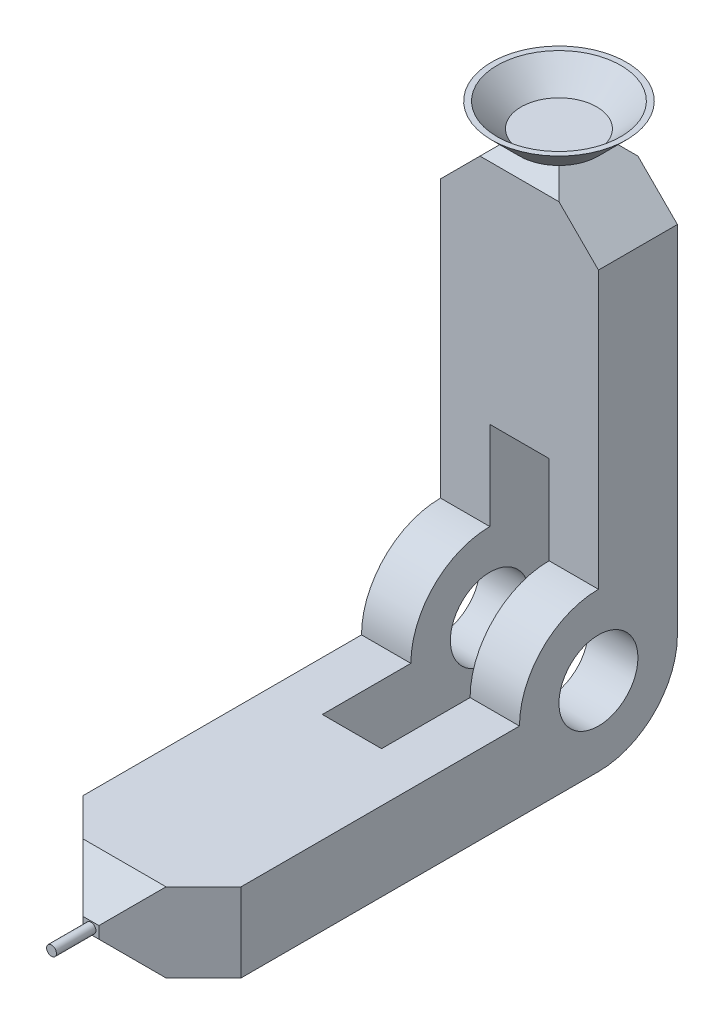
from build123d import *

# Parameters (mm, degrees)
SKETCH1_TOOL_TIP_R  = 10
BOSS_EXTRUDE1_DEPTH = 20
CHAMFER1_SIZE       = 18
CUT_EXTRUDE1_DEPTH  = 7.5
SKETCH3_TOOL_TIP_R  = 1.25
BOSS_EXTRUDE2_DEPTH = 10
CHAMFER2_SIZE       = 15


with BuildPart() as part:
    # sketch1_tool_tip → Boss-Extrude1 (new body, symmetric)
    with BuildSketch(Plane(origin=(0, 0, 0), x_dir=(0, 0, -1), z_dir=(1, 0, 0))):
        with BuildLine():
            Line((-100, 0), (-108.5, -8.5))
            Line((-108.5, -8.5), (-108.5, -11.5))
            Line((-108.5, -11.5), (-100, -20))
            Line((-100, -20), (0, -20))
            ThreePointArc((0, -20), (14.142135624, -14.142135624), (20, 0))
            Line((20, 0), (20, 100))
            Line((20, 100), (15, 105))
            Line((15, 105), (5, 105))
            Line((5, 105), (0, 100))
            Line((0, 100), (0, 20))
            ThreePointArc((0, 20), (-14.142135624, 14.142135624), (-20, 0))
            Line((-20, 0), (-100, 0))
        make_face()
        Circle(SKETCH1_TOOL_TIP_R, mode=Mode.SUBTRACT)
    extrude(amount=BOSS_EXTRUDE1_DEPTH, both=True)

    # Chamfer1
    chamfer1_edges = [part.edges().sort_by_distance(p)[0] for p in [
        (-20, -10, 108.5),
        (20, -10, 108.5),
    ]]
    chamfer(chamfer1_edges, length=CHAMFER1_SIZE)

    # sketch2_tool_tip → Cut-Extrude1 (cut, symmetric)
    with BuildSketch(Plane(origin=(0, 0, 0), x_dir=(0, 0, -1), z_dir=(1, 0, 0))):
        with BuildLine():
            Line((-42.42, -20), (0, -20))
            ThreePointArc((0, -20), (14.142135624, -14.142135624), (20, 0))
            Line((20, 0), (20, 42.42))
            Line((20, 42.42), (0, 42.42))
            Line((0, 42.42), (0, 20))
            ThreePointArc((0, 20), (-14.142135624, 14.142135624), (-20, 0))
            Line((-20, 0), (-42.42, 0))
            Line((-42.42, 0), (-42.42, -20))
        make_face()
    extrude(amount=CUT_EXTRUDE1_DEPTH, both=True, mode=Mode.SUBTRACT)

    # sketch3_tool_tip → Boss-Extrude2 (add)
    with BuildSketch(Plane.XY.offset(108.5)):
        with Locations((0, -10)):
            Circle(SKETCH3_TOOL_TIP_R)
    extrude(amount=BOSS_EXTRUDE2_DEPTH)

    # Chamfer2
    chamfer2_edges = [part.edges().sort_by_distance(p)[0] for p in [
        (-20, 105, -10),
        (20, 105, -10),
    ]]
    chamfer(chamfer2_edges, length=CHAMFER2_SIZE)

    # sketch4_tool_tip → Revolve1 (revolve)
    with BuildSketch(Plane(origin=(0, 0, -10), x_dir=(-1, 0, 0), z_dir=(0, 0, -1))):
        Polygon((0, 105), (10, 105), (17.071067812, 112.071067812), (15.656854249, 112.071067812), (9.585786438, 106), (0, 106), align=None)
    revolve(axis=Axis((0, 105, -10), (0, -1, 0)))


solid = part.part
